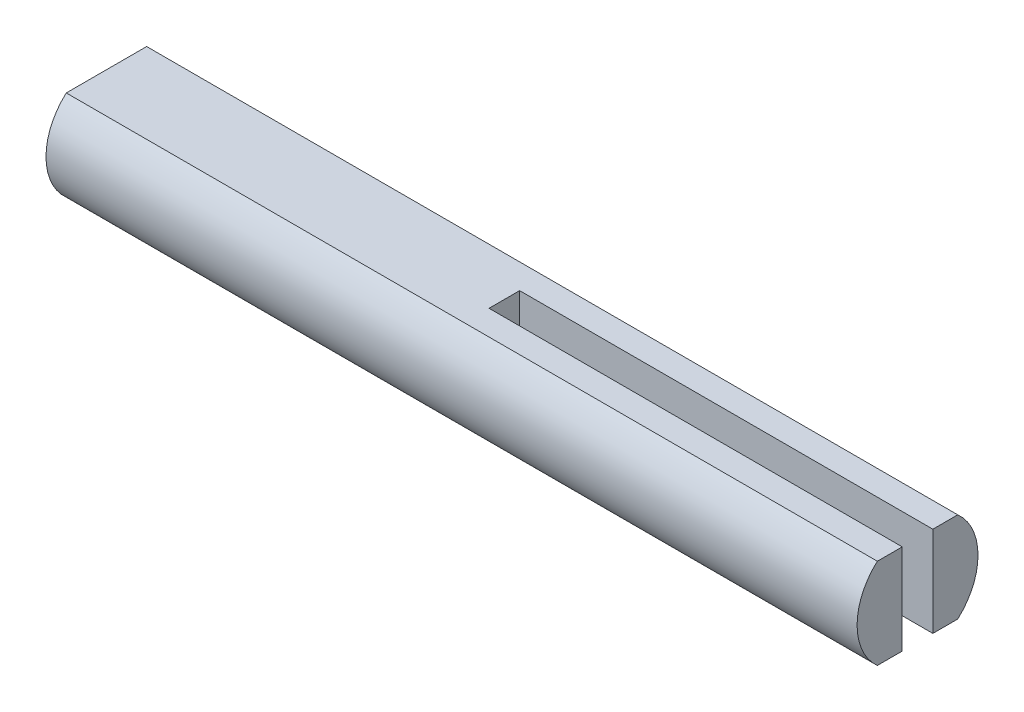
from build123d import *

# Parameters (mm, degrees)
BOSS_EXTRUDE1_DEPTH      = 40.5
BOSS_EXTRUDE1_DEPTH_BACK = 12.5
CUT_EXTRUDE2_DEPTH       = 6.9


with BuildPart() as part:
    # Sketch1 → Boss-Extrude1 (new body, two sides)
    with BuildSketch(Plane(origin=(0, 0, 0), x_dir=(0, 0, -1), z_dir=(1, 0, 0))) as boss_extrude1_sk:
        with BuildLine():
            Line((-2.626785107, 2.95), (2.626785107, 2.95))
            ThreePointArc((2.626785107, 2.95), (3.95, 0), (2.626785107, -2.95))
            Line((2.626785107, -2.95), (-2.626785107, -2.95))
            ThreePointArc((-2.626785107, -2.95), (-3.95, 0), (-2.626785107, 2.95))
        make_face()
    extrude(amount=BOSS_EXTRUDE1_DEPTH)
    extrude(boss_extrude1_sk.sketch, amount=-BOSS_EXTRUDE1_DEPTH_BACK)

    # Sketch5 → Cut-Extrude2 (cut, through all)
    with BuildSketch(Plane(origin=(0, 2.95, 0), x_dir=(1, 0, 0), z_dir=(0, 1, 0))):
        Polygon((40.5, 0), (40.5, 1), (13.5, 1), (13.5, -1), (40.5, -1), align=None)
    extrude(amount=-CUT_EXTRUDE2_DEPTH, mode=Mode.SUBTRACT)


solid = part.part
